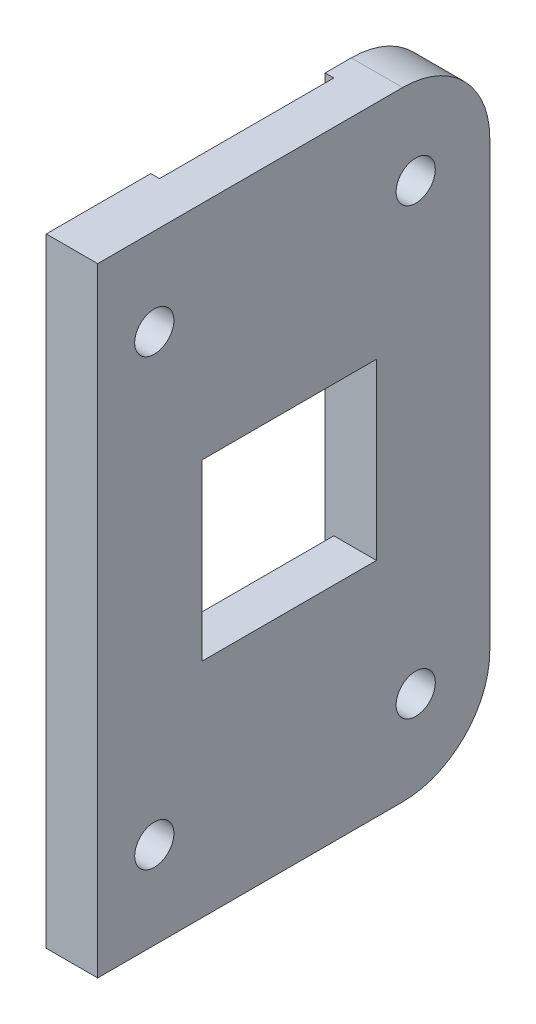
from build123d import *

# Parameters (mm, degrees)
SKETCH1_W           = 5.9
SKETCH1_H           = 45
BOSS_EXTRUDE1_DEPTH = 71
CUT_EXTRUDE2_REACH  = 73
SKETCH3_W           = 1
SKETCH3_H           = 20
FILLET1_R           = 10
CUT_EXTRUDE3_REACH  = 7.9
SKETCH4_R           = 2.25
CUT_EXTRUDE4_REACH  = 7.9
SKETCH5_W           = 20
SKETCH5_H           = 20


with BuildPart() as part:
    # Sketch1 → Boss-Extrude1 (new body)
    with BuildSketch(Plane(origin=(0, 0, 0), x_dir=(1, 0, 0), z_dir=(0, 1, 0))):
        with Locations((2.95, 2.3)):
            Rectangle(SKETCH1_W, SKETCH1_H)
    extrude(amount=BOSS_EXTRUDE1_DEPTH)

    # Sketch3 → Cut-Extrude2 (cut, up to next)
    with BuildSketch(Plane.XZ, mode=Mode.PRIVATE) as cut_extrude2_sk1:
        with Locations((0.5, -1.8)):
            Rectangle(SKETCH3_W, SKETCH3_H)
    cut_extrude2_tool1 = extrude(cut_extrude2_sk1.sketch, amount=-CUT_EXTRUDE2_REACH, mode=Mode.PRIVATE) & part.part
    add(cut_extrude2_tool1.solids().sort_by_distance((0.5, 0, -1.8))[0], mode=Mode.SUBTRACT)

    # Fillet1
    fillet1_edges = [part.edges().sort_by_distance(p)[0] for p in [
        (2.95, 71, -24.8),
        (2.95, 0, -24.8),
    ]]
    fillet(fillet1_edges, radius=FILLET1_R)

    # Sketch4 → Cut-Extrude3 (cut, up to next)
    with BuildSketch(Plane(origin=(5.9, 0, 0), x_dir=(0, 0, -1), z_dir=(1, 0, 0)), mode=Mode.PRIVATE) as cut_extrude3_sk1:
        with Locations((-13.7, 61)):
            Circle(SKETCH4_R)
    cut_extrude3_tool1 = extrude(cut_extrude3_sk1.sketch, amount=-CUT_EXTRUDE3_REACH, mode=Mode.PRIVATE) & part.part
    add(cut_extrude3_tool1.solids().sort_by_distance((5.9, 61, 13.7))[0], mode=Mode.SUBTRACT)
    # Sketch4 → Cut-Extrude3 (cut, up to next)
    with BuildSketch(Plane(origin=(5.9, 0, 0), x_dir=(0, 0, -1), z_dir=(1, 0, 0)), mode=Mode.PRIVATE) as cut_extrude3_sk2:
        with Locations((-13.7, 10)):
            Circle(SKETCH4_R)
    cut_extrude3_tool2 = extrude(cut_extrude3_sk2.sketch, amount=-CUT_EXTRUDE3_REACH, mode=Mode.PRIVATE) & part.part
    add(cut_extrude3_tool2.solids().sort_by_distance((5.9, 10, 13.7))[0], mode=Mode.SUBTRACT)
    # Sketch4 → Cut-Extrude3 (cut, up to next)
    with BuildSketch(Plane(origin=(5.9, 0, 0), x_dir=(0, 0, -1), z_dir=(1, 0, 0)), mode=Mode.PRIVATE) as cut_extrude3_sk3:
        with Locations((16.3, 10)):
            Circle(SKETCH4_R)
    cut_extrude3_tool3 = extrude(cut_extrude3_sk3.sketch, amount=-CUT_EXTRUDE3_REACH, mode=Mode.PRIVATE) & part.part
    add(cut_extrude3_tool3.solids().sort_by_distance((5.9, 10, -16.3))[0], mode=Mode.SUBTRACT)
    # Sketch4 → Cut-Extrude3 (cut, up to next)
    with BuildSketch(Plane(origin=(5.9, 0, 0), x_dir=(0, 0, -1), z_dir=(1, 0, 0)), mode=Mode.PRIVATE) as cut_extrude3_sk4:
        with Locations((16.3, 61)):
            Circle(SKETCH4_R)
    cut_extrude3_tool4 = extrude(cut_extrude3_sk4.sketch, amount=-CUT_EXTRUDE3_REACH, mode=Mode.PRIVATE) & part.part
    add(cut_extrude3_tool4.solids().sort_by_distance((5.9, 61, -16.3))[0], mode=Mode.SUBTRACT)

    # Sketch5 → Cut-Extrude4 (cut, up to next)
    with BuildSketch(Plane(origin=(5.9, 0, 0), x_dir=(0, 0, -1), z_dir=(1, 0, 0)), mode=Mode.PRIVATE) as cut_extrude4_sk1:
        with Locations((1.8, 35.5)):
            Rectangle(SKETCH5_W, SKETCH5_H)
    cut_extrude4_tool1 = extrude(cut_extrude4_sk1.sketch, amount=-CUT_EXTRUDE4_REACH, mode=Mode.PRIVATE) & part.part
    add(cut_extrude4_tool1.solids().sort_by_distance((5.9, 35.5, -1.8))[0], mode=Mode.SUBTRACT)


solid = part.part
